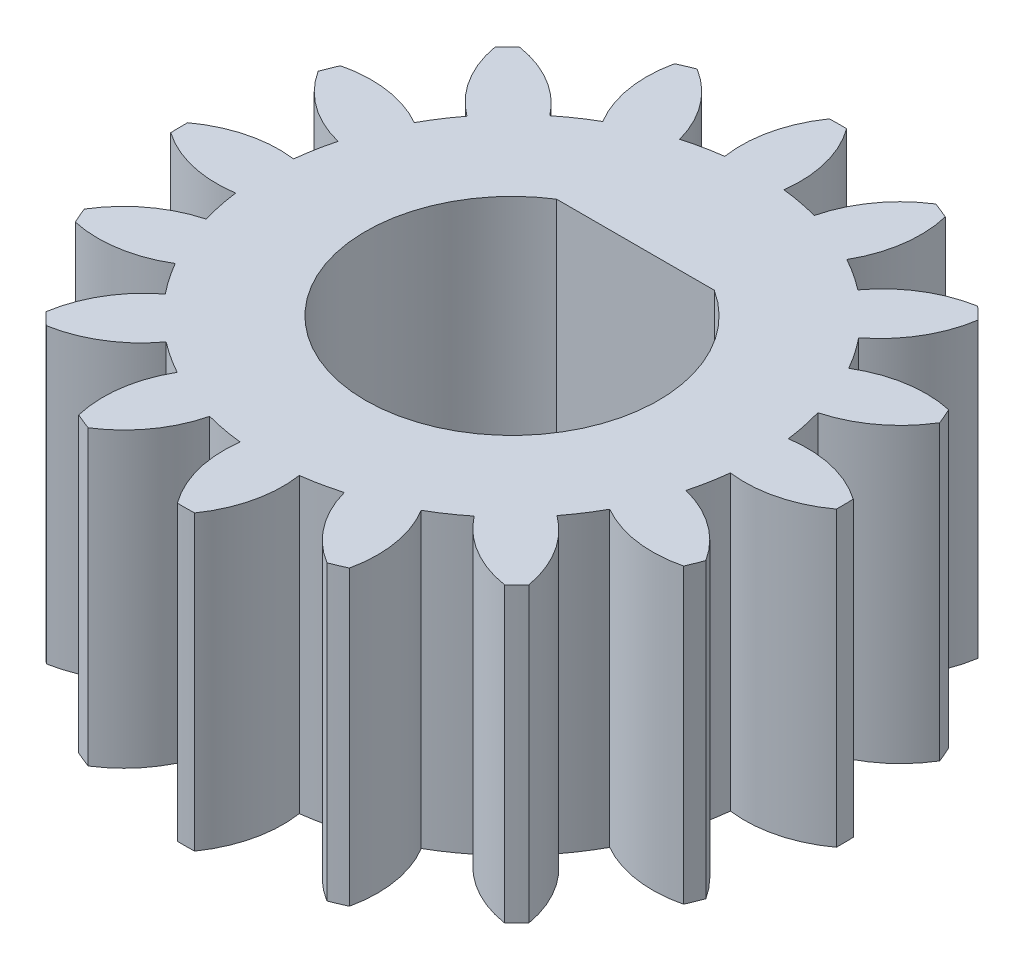
from build123d import *

# Parameters (mm, degrees)
BOSS_EXTRUDE1_DEPTH = 6.35


with BuildPart() as part:
    # Sketch1 → Boss-Extrude1 (new body)
    with BuildSketch(Plane(origin=(0, 0, 0), x_dir=(1, 0, 0), z_dir=(0, 1, 0))):
        with BuildLine():
            ThreePointArc((9.101190716, -14.617505223), (8.787991723, -15.525786229), (8.834558587, -16.485421328))
            ThreePointArc((8.834558587, -16.485421328), (9.005966344, -16.556955762), (9.179175886, -16.624009833))
            ThreePointArc((9.179175886, -16.624009833), (9.877166505, -15.963799948), (10.280004433, -15.09156741))
            ThreePointArc((10.280004433, -15.09156741), (10.682561911, -15.183548614), (11.091017353, -15.244188674))
            ThreePointArc((11.091017353, -15.244188674), (11.149243306, -16.203186971), (11.559501933, -17.07195383))
            ThreePointArc((11.559501933, -17.07195383), (11.745237093, -17.072448121), (11.930922326, -17.068113582))
            ThreePointArc((11.930922326, -17.068113582), (12.323130188, -16.191049737), (12.361514963, -15.231052547))
            ThreePointArc((12.361514963, -15.231052547), (12.768629261, -15.161980021), (13.16919883, -15.061695001))
            ThreePointArc((13.16919883, -15.061695001), (13.589985356, -15.925411791), (14.301477588, -16.571048531))
            ThreePointArc((14.301477588, -16.571048531), (14.473263658, -16.500427428), (14.643155688, -16.425364174))
            ThreePointArc((14.643155688, -16.425364174), (14.669870701, -15.464971388), (14.33795859, -14.563360415))
            ThreePointArc((14.33795859, -14.563360415), (14.687650245, -14.343749825), (15.019350856, -14.09780721))
            ThreePointArc((15.019350856, -14.09780721), (15.738637021, -14.734749443), (16.643044616, -15.058963723))
            ThreePointArc((16.643044616, -15.058963723), (16.774728723, -14.927978648), (16.902963029, -14.793614379))
            ThreePointArc((16.902963029, -14.793614379), (16.560118075, -13.896103748), (15.908439687, -13.19014109))
            ThreePointArc((15.908439687, -13.19014109), (16.147471316, -12.853426158), (16.359804557, -12.499268481))
            ThreePointArc((16.359804557, -12.499268481), (17.268085563, -12.812467475), (18.227720662, -12.76590061))
            ThreePointArc((18.227720662, -12.76590061), (18.299255096, -12.594492854), (18.366309167, -12.421283311))
            ThreePointArc((18.366309167, -12.421283311), (17.706099281, -11.723292693), (16.833866744, -11.320454765))
            ThreePointArc((16.833866744, -11.320454765), (16.925847948, -10.917897287), (16.986488008, -10.509441845))
            ThreePointArc((16.986488008, -10.509441845), (17.945486305, -10.451215891), (18.814253164, -10.040957265))
            ThreePointArc((18.814253164, -10.040957265), (18.814747455, -9.855222104), (18.810412916, -9.669536871))
            ThreePointArc((18.810412916, -9.669536871), (17.93334907, -9.27732901), (16.973351881, -9.238944234))
            ThreePointArc((16.973351881, -9.238944234), (16.904279354, -8.831829937), (16.803994334, -8.431260368))
            ThreePointArc((16.803994334, -8.431260368), (17.667711125, -8.010473841), (18.313347865, -7.29898161))
            ThreePointArc((18.313347865, -7.29898161), (18.242726762, -7.12719554), (18.167663508, -6.957303509))
            ThreePointArc((18.167663508, -6.957303509), (17.207270722, -6.930588496), (16.305659749, -7.262500608))
            ThreePointArc((16.305659749, -7.262500608), (16.086049159, -6.912808952), (15.840106544, -6.581108342))
            ThreePointArc((15.840106544, -6.581108342), (16.477048777, -5.861822176), (16.801263057, -4.957414582))
            ThreePointArc((16.801263057, -4.957414582), (16.670277982, -4.825730474), (16.535913713, -4.697496168))
            ThreePointArc((16.535913713, -4.697496168), (15.638403082, -5.040341123), (14.932440424, -5.69201951))
            ThreePointArc((14.932440424, -5.69201951), (14.595725492, -5.452987882), (14.241567815, -5.240654641))
            ThreePointArc((14.241567815, -5.240654641), (14.554766809, -4.332373635), (14.508199944, -3.372738536))
            ThreePointArc((14.508199944, -3.372738536), (14.336792188, -3.301204102), (14.163582645, -3.234150031))
            ThreePointArc((14.163582645, -3.234150031), (13.465592027, -3.894359916), (13.062754098, -4.766592453))
            ThreePointArc((13.062754098, -4.766592453), (12.66019662, -4.67461125), (12.251741179, -4.61397119))
            ThreePointArc((12.251741179, -4.61397119), (12.193515225, -3.654972893), (11.783256599, -2.786206034))
            ThreePointArc((11.783256599, -2.786206034), (11.597521438, -2.785711743), (11.411836205, -2.790046281))
            ThreePointArc((11.411836205, -2.790046281), (11.019628344, -3.667110127), (10.981243568, -4.627107317))
            ThreePointArc((10.981243568, -4.627107317), (10.574129271, -4.696179843), (10.173559702, -4.796464863))
            ThreePointArc((10.173559702, -4.796464863), (9.752773175, -3.932748072), (9.041280943, -3.287111332))
            ThreePointArc((9.041280943, -3.287111332), (8.869494873, -3.357732436), (8.699602843, -3.43279569))
            ThreePointArc((8.699602843, -3.43279569), (8.67288783, -4.393188476), (9.004799941, -5.294799449))
            ThreePointArc((9.004799941, -5.294799449), (8.655108286, -5.514410038), (8.323407676, -5.760352653))
            ThreePointArc((8.323407676, -5.760352653), (7.60412151, -5.123410421), (6.699713916, -4.799196141))
            ThreePointArc((6.699713916, -4.799196141), (6.568029808, -4.930181216), (6.439795502, -5.064545485))
            ThreePointArc((6.439795502, -5.064545485), (6.782640457, -5.962056116), (7.434318844, -6.668018774))
            ThreePointArc((7.434318844, -6.668018774), (7.195287216, -7.004733706), (6.982953975, -7.358891382))
            ThreePointArc((6.982953975, -7.358891382), (6.074672968, -7.045692389), (5.11503787, -7.092259254))
            ThreePointArc((5.11503787, -7.092259254), (5.043503436, -7.26366701), (4.976449365, -7.436876552))
            ThreePointArc((4.976449365, -7.436876552), (5.63665925, -8.134867171), (6.508891787, -8.537705099))
            ThreePointArc((6.508891787, -8.537705099), (6.416910584, -8.940262577), (6.356270524, -9.348718019))
            ThreePointArc((6.356270524, -9.348718019), (5.397272226, -9.406943972), (4.528505368, -9.817202599))
            ThreePointArc((4.528505368, -9.817202599), (4.528011077, -10.002937759), (4.532345615, -10.188622993))
            ThreePointArc((4.532345615, -10.188622993), (5.409409461, -10.580830854), (6.369406651, -10.61921563))
            ThreePointArc((6.369406651, -10.61921563), (6.438479177, -11.026329927), (6.538764197, -11.426899496))
            ThreePointArc((6.538764197, -11.426899496), (5.675047406, -11.847686023), (5.029410666, -12.559178254))
            ThreePointArc((5.029410666, -12.559178254), (5.10003177, -12.730964324), (5.175095023, -12.900856355))
            ThreePointArc((5.175095023, -12.900856355), (6.13548781, -12.927571367), (7.037098782, -12.595659256))
            ThreePointArc((7.037098782, -12.595659256), (7.256709372, -12.945350911), (7.502651987, -13.277051522))
            ThreePointArc((7.502651987, -13.277051522), (6.865709755, -13.996337688), (6.541495474, -14.900745282))
            ThreePointArc((6.541495474, -14.900745282), (6.672480549, -15.032429389), (6.806844819, -15.160663695))
            ThreePointArc((6.806844819, -15.160663695), (7.70435545, -14.817818741), (8.410318108, -14.166140353))
            ThreePointArc((8.410318108, -14.166140353), (8.74703304, -14.405171982), (9.101190716, -14.617505223))
        make_face()
        with BuildLine():
            Line((9.961117692, -7.254078932), (13.381640839, -7.254078932))
            ThreePointArc((13.381640839, -7.254078932), (11.671379266, -13.104079932), (9.961117692, -7.254078932))
        make_face(mode=Mode.SUBTRACT)
    extrude(amount=BOSS_EXTRUDE1_DEPTH)


solid = part.part
